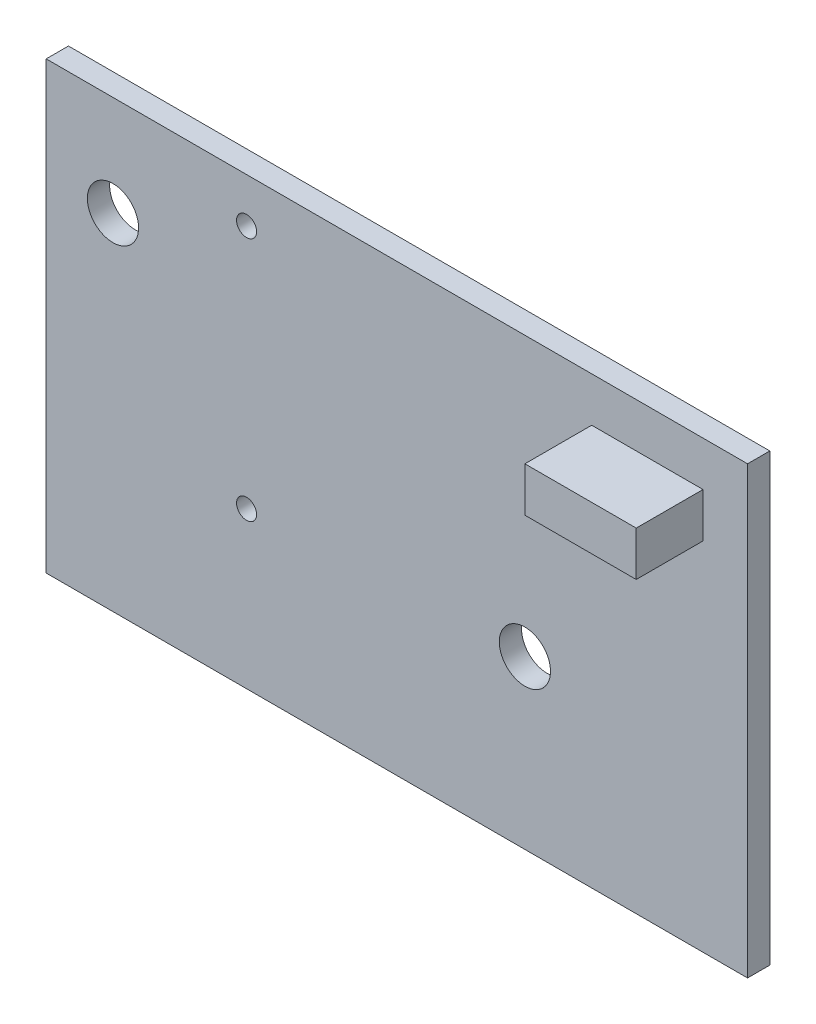
from build123d import *

# Parameters (mm, degrees)
SKETCH_1_W      = 31.5
SKETCH_1_H      = 20
SKETCH_1_R      = 1.15
SKETCH_1_R_2    = 0.45
EXTRUDE_1_DEPTH = 1
SKETCH_2_W      = 5
SKETCH_2_H      = 2
EXTRUDE_2_DEPTH = 3


with BuildPart() as part:
    # Эскиз1 → Бобышка-Вытянуть1 (new body)
    with BuildSketch(Plane.XY):
        with Locations((15.75, 10)):
            Rectangle(SKETCH_1_W, SKETCH_1_H)
        with Locations((3, 15.5)):
            Circle(SKETCH_1_R, mode=Mode.SUBTRACT)
        with Locations((21.5, 7.5)):
            Circle(SKETCH_1_R, mode=Mode.SUBTRACT)
        with Locations((9, 18)):
            Circle(SKETCH_1_R_2, mode=Mode.SUBTRACT)
        with Locations((9, 7)):
            Circle(SKETCH_1_R_2, mode=Mode.SUBTRACT)
    extrude(amount=EXTRUDE_1_DEPTH)

    # Эскиз2 → Бобышка-Вытянуть2 (add)
    with BuildSketch(Plane.XY.offset(1)):
        with Locations((27, 17)):
            Rectangle(SKETCH_2_W, SKETCH_2_H)
    extrude(amount=EXTRUDE_2_DEPTH)


solid = part.part
